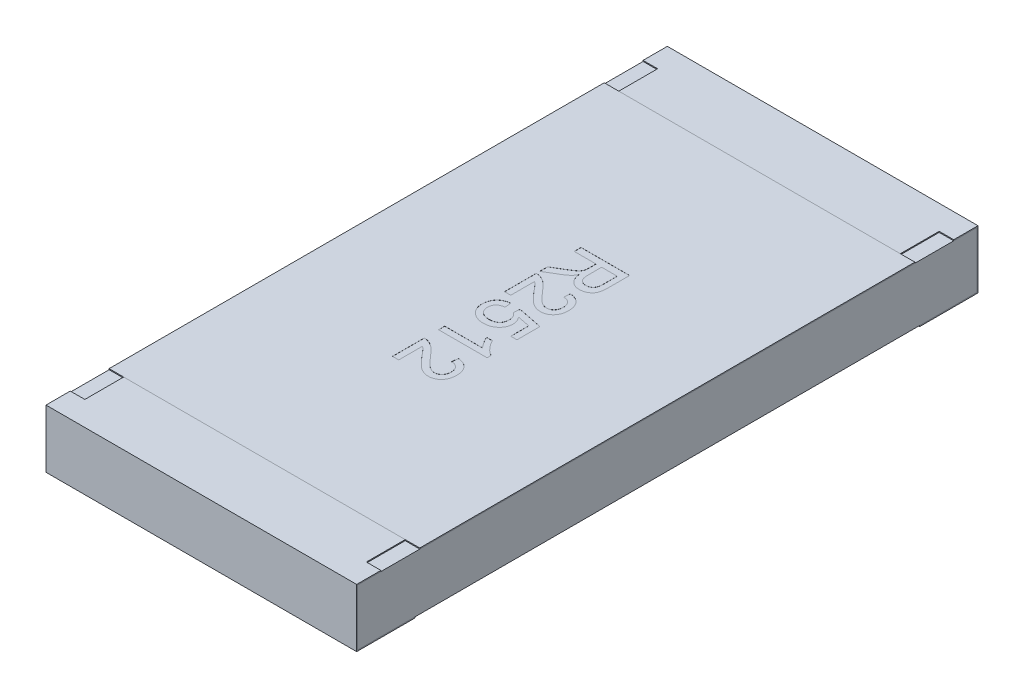
from build123d import *

# Parameters (mm, degrees)
BOSS_EXTRUDE2_DEPTH   = 1.6
BOSS_EXTRUDE2_2_DEPTH = 1.6
BOSS_EXTRUDE3_START   = -1.6
SKETCH5_W             = 6.38
SKETCH5_H             = 0.58
BOSS_EXTRUDE3_DEPTH   = 3.2
SKETCH6_W             = 0.15
SKETCH6_H             = 0.4
CUT_EXTRUDE1_DEPTH    = 0.01
SKETCH7_W             = 3.2
SKETCH7_H             = 5.1
BOSS_EXTRUDE4_DEPTH   = 0.01
TEXT2512_DEPTH        = 0.001


with BuildPart() as part:
    # Sketch4 → Boss-Extrude2 (new body, symmetric)
    with BuildSketch(Plane(origin=(0, 0, 0), x_dir=(0, 0, -1), z_dir=(1, 0, 0))):
        Polygon((-3.2, 0.3), (-3.2, -0.3), (-2.6, -0.3), (-2.6, -0.29), (-3.19, -0.29), (-3.19, 0.29), (-2.55, 0.29), (-2.55, 0.3), align=None)
    extrude(amount=BOSS_EXTRUDE2_DEPTH, both=True)


with BuildPart() as body_2:
    # Sketch4 → Boss-Extrude2 2 (new body, symmetric)
    with BuildSketch(Plane(origin=(0, 0, 0), x_dir=(0, 0, -1), z_dir=(1, 0, 0))):
        Polygon((2.55, 0.3), (3.2, 0.3), (3.2, -0.3), (2.6, -0.3), (2.6, -0.29), (3.19, -0.29), (3.19, 0.29), (2.55, 0.29), align=None)
    extrude(amount=BOSS_EXTRUDE2_2_DEPTH, both=True)


with BuildPart() as body_3:
    # Sketch5 → Boss-Extrude3 (new body)
    with BuildSketch(Plane(origin=(0, 0, 0), x_dir=(0, 0, -1), z_dir=(1, 0, 0)).offset(BOSS_EXTRUDE3_START)):
        Rectangle(SKETCH5_W, SKETCH5_H)
    extrude(amount=BOSS_EXTRUDE3_DEPTH)


with BuildPart() as cut_extrude1_tool:
    # Sketch6 → Cut-Extrude1 (new body)
    with BuildSketch(Plane(origin=(0, 0.3, 0), x_dir=(1, 0, 0), z_dir=(0, 1, 0))):
        with Locations((-1.525, 2.75)):
            Rectangle(SKETCH6_W, SKETCH6_H)
        with Locations((1.525, 2.75)):
            Rectangle(SKETCH6_W, SKETCH6_H)
        with Locations((1.525, -2.75)):
            Rectangle(SKETCH6_W, SKETCH6_H)
        with Locations((-1.525, -2.75)):
            Rectangle(SKETCH6_W, SKETCH6_H)
    extrude(amount=-CUT_EXTRUDE1_DEPTH)


with BuildPart() as part_1:
    add(part.part)

    # Cut-Extrude1: cut by cut_extrude1_tool
    add(cut_extrude1_tool.part, mode=Mode.SUBTRACT)


with BuildPart() as body_2_1:
    add(body_2.part)

    # Cut-Extrude1: cut by cut_extrude1_tool
    add(cut_extrude1_tool.part, mode=Mode.SUBTRACT)


with BuildPart() as body_4:
    # Sketch7 → Boss-Extrude4 (new body)
    with BuildSketch(Plane(origin=(0, 0.29, 0), x_dir=(1, 0, 0), z_dir=(0, 1, 0))):
        Rectangle(SKETCH7_W, SKETCH7_H)
    extrude(amount=BOSS_EXTRUDE4_DEPTH)

    # Sketch16 → TEXT2512 (cut)
    with BuildSketch(Plane(origin=(0, 0.3, 0), x_dir=(1, 0, 0), z_dir=(0, 1, 0))):
        with BuildLine():
            Line((-0.25, 0.961538462), (0.25, 0.961538462))
            Line((0.25, 0.961538462), (0.25, 0.744591346))
            add(Edge.make_bspline(
                [(0.25, 0.744591346), (0.249960163, 0.739482882), (0.249883063, 0.729596046), (0.249332125, 0.71525849), (0.248161656, 0.70190744), (0.246854386, 0.689458751), (0.244924176, 0.677933725), (0.242659692, 0.667326869), (0.239983333, 0.657678866), (0.236819773, 0.648916292), (0.233241826, 0.640785908), (0.228824875, 0.633251678), (0.223992823, 0.62599069), (0.218269952, 0.619290183), (0.212116317, 0.612856855), (0.205227709, 0.606910547), (0.197701412, 0.601422238), (0.18694151, 0.594650155), (0.17253828, 0.58752438), (0.154200832, 0.581442549), (0.134978762, 0.577554129), (0.121846978, 0.577135485), (0.115184295, 0.576923077)],
                knots=[0, 0, 0, 0, 1.5326e-05, 2.9661e-05, 4.3028e-05, 5.5527e-05, 6.7202e-05, 7.8066e-05, 8.8054e-05, 9.721e-05, 0.000105997, 0.000114656, 0.000123379, 0.000132125, 0.00014105, 0.000150068, 0.000159383, 0.00016897, 0.000188187, 0.000207412, 0.0002268, 0.000246768, 0.000246768, 0.000246768, 0.000246768], degree=3))
            add(Edge.make_bspline(
                [(0.115184295, 0.576923077), (0.110907215, 0.577020919), (0.10245969, 0.577214164), (0.090039553, 0.578694416), (0.078172662, 0.581372871), (0.066754852, 0.584807275), (0.055948764, 0.589508619), (0.045530439, 0.594952466), (0.035798164, 0.601706001), (0.026427897, 0.609247173), (0.017837878, 0.618014302), (0.00991265, 0.627773521), (0.003065461, 0.63877045), (-0.003087965, 0.650802727), (-0.008472636, 0.663892184), (-0.013000013, 0.678125865), (-0.016544481, 0.693453368), (-0.01831997, 0.704082614), (-0.019230769, 0.709535256)],
                knots=[0, 0, 0, 0, 1.283e-05, 2.5341e-05, 3.7443e-05, 4.9292e-05, 6.1049e-05, 7.2745e-05, 8.4496e-05, 9.6525e-05, 0.000108778, 0.000121245, 0.000134166, 0.00014756, 0.000161752, 0.000176576, 0.00019232, 0.000208902, 0.000208902, 0.000208902, 0.000208902], degree=3))
            add(Edge.make_bspline(
                [(-0.019230769, 0.709535256), (-0.021256287, 0.705504887), (-0.025089867, 0.697876841), (-0.03124439, 0.687355267), (-0.037334993, 0.678320187), (-0.041788652, 0.673108774), (-0.043870192, 0.670673077)],
                knots=[0, 0, 0, 0, 1.3529e-05, 2.5605e-05, 3.6551e-05, 4.6157e-05, 4.6157e-05, 4.6157e-05, 4.6157e-05], degree=3))
            add(Edge.make_bspline(
                [(-0.043870192, 0.670673077), (-0.048494022, 0.665941745), (-0.057976735, 0.656238563), (-0.074278364, 0.642997304), (-0.09220549, 0.629895236), (-0.105269317, 0.622029028), (-0.111979167, 0.617988782)],
                knots=[0, 0, 0, 0, 1.9831e-05, 4.0671e-05, 6.291e-05, 8.6395e-05, 8.6395e-05, 8.6395e-05, 8.6395e-05], degree=3))
            Line((-0.111979167, 0.617988782), (-0.25, 0.535957532))
            Line((-0.25, 0.535957532), (-0.25, 0.616786859))
            Line((-0.25, 0.616786859), (-0.14443109, 0.679086538))
            add(Edge.make_bspline(
                [(-0.14443109, 0.679086538), (-0.14072714, 0.681326614), (-0.133549493, 0.685667513), (-0.123065864, 0.691936276), (-0.113417718, 0.698088149), (-0.104312641, 0.70377527), (-0.095987375, 0.709301847), (-0.088193556, 0.714357531), (-0.081239279, 0.719331295), (-0.072863649, 0.725115849), (-0.063747422, 0.732089965), (-0.054441051, 0.740283365), (-0.046842147, 0.74788595), (-0.039501217, 0.75739782), (-0.032660963, 0.769200756), (-0.029482057, 0.779212651), (-0.027944712, 0.784054487)],
                knots=[0, 0, 0, 0, 1.2986e-05, 2.5165e-05, 3.6642e-05, 4.7312e-05, 5.7369e-05, 6.6619e-05, 7.5178e-05, 8.3014e-05, 9.7157e-05, 0.000109576, 0.000120201, 0.000129337, 0.000145574, 0.000160781, 0.000160781, 0.000160781, 0.000160781], degree=3))
            add(Edge.make_bspline(
                [(-0.027944712, 0.784054487), (-0.027578209, 0.786086843), (-0.026741472, 0.790726773), (-0.026194997, 0.798605362), (-0.025614988, 0.808151239), (-0.025631888, 0.815069299), (-0.025641026, 0.818810096)],
                knots=[0, 0, 0, 0, 6.191e-06, 1.4135e-05, 2.3663e-05, 3.4882e-05, 3.4882e-05, 3.4882e-05, 3.4882e-05], degree=3))
            Line((-0.025641026, 0.818810096), (-0.025641026, 0.891025641))
            Line((-0.025641026, 0.891025641), (-0.25, 0.891025641))
            Line((-0.25, 0.891025641), (-0.25, 0.961538462))
        make_face()
        with BuildLine():
            Line((0.032051282, 0.891025641), (0.032051282, 0.757111378))
            add(Edge.make_bspline(
                [(0.032051282, 0.757111378), (0.032156765, 0.750396498), (0.032353956, 0.737843659), (0.034025946, 0.720289204), (0.036712066, 0.705301709), (0.0405672, 0.692601432), (0.045943674, 0.681937096), (0.052623746, 0.672775428), (0.060751598, 0.664981424), (0.07009756, 0.658611575), (0.080294979, 0.653594523), (0.091082454, 0.65016958), (0.102226625, 0.647783442), (0.10982965, 0.647552772), (0.113681891, 0.647435897)],
                knots=[0, 0, 0, 0, 2.0141e-05, 3.7652e-05, 5.2837e-05, 6.5761e-05, 7.7318e-05, 8.8497e-05, 9.9618e-05, 0.000110925, 0.000122303, 0.000133579, 0.000144815, 0.000156355, 0.000156355, 0.000156355, 0.000156355], degree=3))
            add(Edge.make_bspline(
                [(0.113681891, 0.647435897), (0.116488464, 0.647528961), (0.121985715, 0.647711246), (0.130054155, 0.648666841), (0.137721037, 0.650524745), (0.14502689, 0.652978104), (0.151918204, 0.656256288), (0.158448379, 0.660150637), (0.164581222, 0.664797798), (0.170335414, 0.670120854), (0.175571167, 0.676232689), (0.180088486, 0.683213842), (0.183927233, 0.691009252), (0.186973919, 0.69962798), (0.189410772, 0.709042877), (0.191031932, 0.719307538), (0.192204997, 0.730375021), (0.192272821, 0.738044145), (0.192307692, 0.741987179)],
                knots=[0, 0, 0, 0, 8.423e-06, 1.6498e-05, 2.4321e-05, 3.205e-05, 3.9577e-05, 4.7169e-05, 5.4822e-05, 6.2617e-05, 7.0646e-05, 7.8897e-05, 8.7497e-05, 9.6653e-05, 0.000106273, 0.000116631, 0.000127803, 0.000139626, 0.000139626, 0.000139626, 0.000139626], degree=3))
            Line((0.192307692, 0.741987179), (0.192307692, 0.891025641))
            Line((0.192307692, 0.891025641), (0.032051282, 0.891025641))
        make_face(mode=Mode.SUBTRACT)
        with BuildLine():
            Line((-0.185897436, 0.173076923), (-0.25, 0.173076923))
            Line((-0.25, 0.173076923), (-0.25, 0.5))
            add(Edge.make_bspline(
                [(-0.25, 0.5), (-0.246190204, 0.500006693), (-0.238583383, 0.500020056), (-0.227333376, 0.49873286), (-0.21623261, 0.496716852), (-0.209114131, 0.494437353), (-0.205528846, 0.493289263)],
                knots=[0, 0, 0, 0, 1.142e-05, 2.2802e-05, 3.392e-05, 4.5202e-05, 4.5202e-05, 4.5202e-05, 4.5202e-05], degree=3))
            add(Edge.make_bspline(
                [(-0.205528846, 0.493289263), (-0.199672194, 0.491165902), (-0.187747085, 0.486842389), (-0.170501435, 0.478116399), (-0.153461868, 0.467682166), (-0.139489569, 0.457696378), (-0.128408004, 0.448499455), (-0.11963342, 0.44091536), (-0.110764129, 0.432372029), (-0.101641984, 0.423025206), (-0.092266458, 0.412931612), (-0.082593861, 0.402091641), (-0.07280804, 0.390373176), (-0.066321448, 0.382192631), (-0.063000801, 0.378004808)],
                knots=[0, 0, 0, 0, 1.8675e-05, 3.8026e-05, 5.7849e-05, 7.8586e-05, 8.9474e-05, 0.000101045, 0.000113371, 0.000126404, 0.000140223, 0.000154696, 0.000169983, 0.000186016, 0.000186016, 0.000186016, 0.000186016], degree=3))
            add(Edge.make_bspline(
                [(-0.063000801, 0.378004808), (-0.057585784, 0.371571255), (-0.047158825, 0.35918304), (-0.031686185, 0.341688941), (-0.017318962, 0.325710928), (-0.003805341, 0.311503434), (0.008723604, 0.298950257), (0.020239487, 0.288021922), (0.03070637, 0.278624397), (0.040503108, 0.270872408), (0.049753955, 0.264331817), (0.058777584, 0.258789244), (0.06773162, 0.254170244), (0.076587728, 0.250323236), (0.085383783, 0.247280579), (0.094145409, 0.245206576), (0.102785672, 0.243800058), (0.108534999, 0.243659335), (0.111378205, 0.243589744)],
                knots=[0, 0, 0, 0, 2.5226e-05, 4.8575e-05, 7.0061e-05, 8.9685e-05, 0.000107391, 0.000123262, 0.00013731, 0.000149574, 0.000160717, 0.000171282, 0.000181316, 0.000190917, 0.000200229, 0.000209193, 0.000217905, 0.000226428, 0.000226428, 0.000226428, 0.000226428], degree=3))
            add(Edge.make_bspline(
                [(0.111378205, 0.243589744), (0.114188238, 0.243659344), (0.119701369, 0.243795895), (0.127769802, 0.245091488), (0.135539896, 0.246895058), (0.14287177, 0.249810882), (0.149982559, 0.253281588), (0.156647535, 0.257733617), (0.163032944, 0.262883656), (0.168969907, 0.268780184), (0.17454131, 0.275219933), (0.179166687, 0.282417853), (0.183368098, 0.289917042), (0.186646742, 0.297965351), (0.189173495, 0.3064911), (0.190933763, 0.315480614), (0.192071797, 0.324957896), (0.192227868, 0.331426935), (0.192307692, 0.334735577)],
                knots=[0, 0, 0, 0, 8.423e-06, 1.6525e-05, 2.4469e-05, 3.23e-05, 4.0139e-05, 4.8167e-05, 5.6286e-05, 6.4714e-05, 7.3243e-05, 8.1771e-05, 9.0332e-05, 9.9e-05, 0.000107778, 0.000116971, 0.00012645, 0.000136374, 0.000136374, 0.000136374, 0.000136374], degree=3))
            add(Edge.make_bspline(
                [(0.192307692, 0.334735577), (0.192227732, 0.338211016), (0.192071243, 0.345012707), (0.190936175, 0.354956033), (0.189191722, 0.364391456), (0.186569692, 0.373285324), (0.183136978, 0.381619852), (0.179045534, 0.389454122), (0.174196706, 0.396758181), (0.168565002, 0.403415143), (0.162430447, 0.40958156), (0.155494268, 0.414790829), (0.148121475, 0.419344442), (0.140077995, 0.422936663), (0.131540513, 0.425866234), (0.122382293, 0.42798081), (0.11264261, 0.429136521), (0.105972365, 0.429368597), (0.102564103, 0.429487179)],
                knots=[0, 0, 0, 0, 1.0424e-05, 2.0401e-05, 2.9987e-05, 3.9178e-05, 4.8162e-05, 5.6988e-05, 6.5655e-05, 7.4401e-05, 8.3113e-05, 9.1687e-05, 0.000100362, 0.000109057, 0.000118053, 0.000127407, 0.000137196, 0.000147425, 0.000147425, 0.000147425, 0.000147425], degree=3))
            Line((0.102564103, 0.429487179), (0.108974359, 0.493589744))
            add(Edge.make_bspline(
                [(0.108974359, 0.493589744), (0.114561103, 0.492933952), (0.125429633, 0.491658166), (0.141170053, 0.488479075), (0.15581619, 0.484020626), (0.169558239, 0.478669774), (0.182228095, 0.472010838), (0.193871977, 0.464291075), (0.20454309, 0.455516505), (0.213993267, 0.445534327), (0.222618938, 0.434726607), (0.229876147, 0.422825241), (0.236164414, 0.410106323), (0.241249058, 0.396479333), (0.245145041, 0.381949617), (0.247930691, 0.366539805), (0.249649875, 0.350232454), (0.249881626, 0.339046748), (0.25, 0.333333333)],
                knots=[0, 0, 0, 0, 1.6871e-05, 3.2822e-05, 4.8095e-05, 6.2751e-05, 7.6998e-05, 9.0943e-05, 0.000104601, 0.000118344, 0.000132109, 0.000146007, 0.000160072, 0.00017462, 0.000189563, 0.000205142, 0.000221557, 0.000238695, 0.000238695, 0.000238695, 0.000238695], degree=3))
            add(Edge.make_bspline(
                [(0.25, 0.333333333), (0.24990096, 0.327551577), (0.249708029, 0.316288681), (0.247735103, 0.299876528), (0.244659885, 0.284392341), (0.240382222, 0.269774143), (0.234732773, 0.2560996), (0.227928529, 0.243321893), (0.219852523, 0.23148148), (0.210540088, 0.220739103), (0.200369372, 0.211051738), (0.189509921, 0.20257465), (0.178049555, 0.19544786), (0.166021375, 0.189553027), (0.153347568, 0.1850393), (0.140075652, 0.181898053), (0.126237909, 0.179753804), (0.116795268, 0.179577236), (0.111979167, 0.179487179)],
                knots=[0, 0, 0, 0, 1.7338e-05, 3.3775e-05, 4.9509e-05, 6.4657e-05, 7.9389e-05, 9.3818e-05, 0.000108014, 0.000122289, 0.000136388, 0.000150092, 0.000163543, 0.000176803, 0.000190204, 0.000203808, 0.000217675, 0.000232111, 0.000232111, 0.000232111, 0.000232111], degree=3))
            add(Edge.make_bspline(
                [(0.111979167, 0.179487179), (0.107030663, 0.179622369), (0.097122734, 0.179893045), (0.082332055, 0.182085171), (0.067657262, 0.18561383), (0.052981733, 0.190510113), (0.038292684, 0.197324189), (0.023237391, 0.205716263), (0.007927337, 0.216205215), (-0.005185376, 0.226152299), (-0.016100688, 0.235517739), (-0.025104319, 0.243819078), (-0.034707985, 0.253420875), (-0.045099702, 0.264067794), (-0.056125829, 0.275977903), (-0.067952516, 0.288934167), (-0.080329296, 0.303193922), (-0.088782578, 0.313094888), (-0.093149038, 0.318209135)],
                knots=[0, 0, 0, 0, 1.484e-05, 2.9713e-05, 4.4751e-05, 6.0081e-05, 7.6038e-05, 9.3257e-05, 0.000111731, 0.000131664, 0.000142604, 0.000154866, 0.000168394, 0.000183339, 0.000199497, 0.000217082, 0.000235964, 0.000256139, 0.000256139, 0.000256139, 0.000256139], degree=3))
            add(Edge.make_bspline(
                [(-0.093149038, 0.318209135), (-0.096714295, 0.32258863), (-0.103512691, 0.330939655), (-0.113369606, 0.342819654), (-0.122404327, 0.353463804), (-0.1303383, 0.363106863), (-0.137487823, 0.371422094), (-0.143708014, 0.378587846), (-0.149086369, 0.384532965), (-0.157337473, 0.393595996), (-0.169000351, 0.405162111), (-0.180421993, 0.413615691), (-0.185897436, 0.417668269)],
                knots=[0, 0, 0, 0, 1.6942e-05, 3.2305e-05, 4.6309e-05, 5.8826e-05, 6.9766e-05, 7.9207e-05, 8.7292e-05, 9.3814e-05, 0.000115985, 0.0001364, 0.0001364, 0.0001364, 0.0001364], degree=3))
            Line((-0.185897436, 0.417668269), (-0.185897436, 0.173076923))
        make_face()
        with BuildLine():
            Line((-0.115384615, 0.102564103), (-0.108974359, 0.038461538))
            add(Edge.make_bspline(
                [(-0.108974359, 0.038461538), (-0.112586187, 0.037826822), (-0.119611753, 0.036592201), (-0.129781469, 0.034239494), (-0.13922942, 0.031183996), (-0.148037429, 0.027750809), (-0.156112364, 0.023669886), (-0.163581723, 0.019248172), (-0.170180368, 0.014033665), (-0.176253413, 0.008551311), (-0.18160484, 0.002534008), (-0.186116278, -0.004076306), (-0.190052234, -0.011095199), (-0.19327482, -0.018608158), (-0.195633584, -0.026626698), (-0.19749896, -0.035048764), (-0.198438915, -0.043982805), (-0.198623748, -0.050078441), (-0.198717949, -0.053185096)],
                knots=[0, 0, 0, 0, 1.1001e-05, 2.1399e-05, 3.1282e-05, 4.0768e-05, 4.9726e-05, 5.8401e-05, 6.6755e-05, 7.4908e-05, 8.2926e-05, 9.0845e-05, 9.887e-05, 0.000107038, 0.000115307, 0.000123912, 0.000132882, 0.000142206, 0.000142206, 0.000142206, 0.000142206], degree=3))
            add(Edge.make_bspline(
                [(-0.198717949, -0.053185096), (-0.19862586, -0.056996266), (-0.198445776, -0.064449175), (-0.196922698, -0.075291747), (-0.19441132, -0.085533433), (-0.190896833, -0.09512523), (-0.186526152, -0.104179583), (-0.180866916, -0.112396119), (-0.174505377, -0.120222849), (-0.1669212, -0.127156121), (-0.158664557, -0.133467346), (-0.14965208, -0.138914408), (-0.140010266, -0.143500065), (-0.129740964, -0.147360686), (-0.118785509, -0.150211474), (-0.107202181, -0.152308458), (-0.094983602, -0.153654638), (-0.086608825, -0.15378141), (-0.082331731, -0.153846154)],
                knots=[0, 0, 0, 0, 1.1429e-05, 2.235e-05, 3.2772e-05, 4.3006e-05, 5.2951e-05, 6.284e-05, 7.2869e-05, 8.3144e-05, 9.3581e-05, 0.000104008, 0.00011467, 0.000125572, 0.00013687, 0.000148579, 0.000160867, 0.000173694, 0.000173694, 0.000173694, 0.000173694], degree=3))
            add(Edge.make_bspline(
                [(-0.082331731, -0.153846154), (-0.078255716, -0.153772567), (-0.07031877, -0.153629277), (-0.058761256, -0.152422538), (-0.047893696, -0.150386627), (-0.037596309, -0.14775235), (-0.028030005, -0.14412133), (-0.019056083, -0.139814737), (-0.010864994, -0.134538979), (-0.003201699, -0.12866935), (0.003668137, -0.121965493), (0.009468842, -0.11433684), (0.014545632, -0.106082658), (0.018662591, -0.097036699), (0.021721337, -0.087193637), (0.024074767, -0.076651285), (0.025312575, -0.06530025), (0.025529575, -0.057494552), (0.025641026, -0.053485577)],
                knots=[0, 0, 0, 0, 1.2226e-05, 2.3807e-05, 3.4808e-05, 4.5377e-05, 5.5646e-05, 6.5456e-05, 7.5181e-05, 8.4818e-05, 9.4379e-05, 0.000103876, 0.000113495, 0.000123401, 0.000133601, 0.000144367, 0.00015576, 0.000167789, 0.000167789, 0.000167789, 0.000167789], degree=3))
            add(Edge.make_bspline(
                [(0.025641026, -0.053485577), (0.025491387, -0.048501405), (0.025203425, -0.038909959), (0.022894783, -0.025162111), (0.019038767, -0.012672912), (0.01340113, -0.001566177), (0.006631659, 0.008378684), (-0.001024126, 0.01734517), (-0.009565812, 0.025405836), (-0.015996531, 0.02982748), (-0.019230769, 0.032051282)],
                knots=[0, 0, 0, 0, 1.4945e-05, 2.8761e-05, 4.1685e-05, 5.4003e-05, 6.5976e-05, 7.7698e-05, 8.9321e-05, 0.000101081, 0.000101081, 0.000101081, 0.000101081], degree=3))
            Line((-0.019230769, 0.032051282), (-0.012820513, 0.096153846))
            Line((-0.012820513, 0.096153846), (0.243589744, 0.044871795))
            Line((0.243589744, 0.044871795), (0.243589744, -0.192307692))
            Line((0.243589744, -0.192307692), (0.179487179, -0.192307692))
            Line((0.179487179, -0.192307692), (0.179487179, -0.007512019))
            Line((0.179487179, -0.007512019), (0.049979968, 0.017928686))
            add(Edge.make_bspline(
                [(0.049979968, 0.017928686), (0.052633796, 0.014391519), (0.057845494, 0.007445083), (0.064676088, -0.003387375), (0.070394853, -0.014357876), (0.075181731, -0.025408727), (0.078783961, -0.036693128), (0.081359847, -0.048088137), (0.08307819, -0.059610163), (0.083248043, -0.067334987), (0.083333333, -0.071213942)],
                knots=[0, 0, 0, 0, 1.3262e-05, 2.6045e-05, 3.8365e-05, 5.0347e-05, 6.213e-05, 7.3841e-05, 8.5372e-05, 9.7001e-05, 9.7001e-05, 9.7001e-05, 9.7001e-05], degree=3))
            add(Edge.make_bspline(
                [(0.083333333, -0.071213942), (0.083201063, -0.076262289), (0.08294059, -0.086203708), (0.080800473, -0.100852729), (0.077167497, -0.114859675), (0.072274361, -0.12833433), (0.065787848, -0.141099331), (0.05793341, -0.153282781), (0.048649322, -0.164840083), (0.038099128, -0.175688124), (0.026437841, -0.185568095), (0.013856148, -0.194227164), (0.000442132, -0.201594647), (-0.013788726, -0.207598467), (-0.028861807, -0.212229812), (-0.044692889, -0.215484058), (-0.061343963, -0.217552338), (-0.072710105, -0.217814554), (-0.078525641, -0.217948718)],
                knots=[0, 0, 0, 0, 1.514e-05, 2.9815e-05, 4.4294e-05, 5.849e-05, 7.2735e-05, 8.7154e-05, 0.000101905, 0.000117133, 0.000132484, 0.000147681, 0.000162877, 0.000178318, 0.000193937, 0.000210103, 0.000226751, 0.000244193, 0.000244193, 0.000244193, 0.000244193], degree=3))
            add(Edge.make_bspline(
                [(-0.078525641, -0.217948718), (-0.084072884, -0.217836269), (-0.095030272, -0.21761415), (-0.111172579, -0.215761686), (-0.126756663, -0.21278891), (-0.141710465, -0.208535612), (-0.156166252, -0.203257401), (-0.169945746, -0.196570051), (-0.18332252, -0.188924355), (-0.191564851, -0.182779932), (-0.195713141, -0.1796875)],
                knots=[0, 0, 0, 0, 1.6637e-05, 3.2864e-05, 4.8677e-05, 6.4182e-05, 7.9457e-05, 9.4779e-05, 0.000110085, 0.000125594, 0.000125594, 0.000125594, 0.000125594], degree=3))
            add(Edge.make_bspline(
                [(-0.195713141, -0.1796875), (-0.200555889, -0.175759844), (-0.210082093, -0.168033722), (-0.222446537, -0.154656027), (-0.232954612, -0.140274815), (-0.241491662, -0.124804503), (-0.248351904, -0.108348946), (-0.252917137, -0.090705993), (-0.255982873, -0.072088829), (-0.256265835, -0.059307785), (-0.256410256, -0.052784455)],
                knots=[0, 0, 0, 0, 1.8686e-05, 3.6757e-05, 5.4468e-05, 7.1998e-05, 8.965e-05, 0.000107799, 0.000126555, 0.000146107, 0.000146107, 0.000146107, 0.000146107], degree=3))
            add(Edge.make_bspline(
                [(-0.256410256, -0.052784455), (-0.256301101, -0.047403749), (-0.256087571, -0.036878006), (-0.254231508, -0.021466356), (-0.251271122, -0.006808399), (-0.247027162, 0.007102053), (-0.241657017, 0.020301146), (-0.234875977, 0.032632177), (-0.227022789, 0.044259002), (-0.217999763, 0.055031487), (-0.208043427, 0.064976767), (-0.197057937, 0.073675716), (-0.185346654, 0.081325758), (-0.172944192, 0.088028278), (-0.159606333, 0.093245894), (-0.145600701, 0.097614269), (-0.130789038, 0.100853553), (-0.120573263, 0.101987941), (-0.115384615, 0.102564103)],
                knots=[0, 0, 0, 0, 1.6137e-05, 3.1567e-05, 4.6496e-05, 6.0944e-05, 7.5136e-05, 8.9165e-05, 0.000103083, 0.000117164, 0.000131258, 0.000145227, 0.000159117, 0.000173187, 0.000187434, 0.000202007, 0.000217173, 0.000232827, 0.000232827, 0.000232827, 0.000232827], degree=3))
        make_face()
        with BuildLine():
            Line((-0.25, -0.506410256), (-0.25, -0.442307692))
            Line((-0.25, -0.442307692), (0.139623397, -0.442307692))
            add(Edge.make_bspline(
                [(0.139623397, -0.442307692), (0.136064182, -0.438616449), (0.128666742, -0.430944606), (0.118190939, -0.417980505), (0.107619408, -0.403514084), (0.097315673, -0.387785327), (0.08780582, -0.371628763), (0.079128194, -0.356062824), (0.071822591, -0.341304921), (0.067824115, -0.33158647), (0.065905449, -0.326923077)],
                knots=[0, 0, 0, 0, 1.5377e-05, 3.1959e-05, 4.9949e-05, 6.9117e-05, 8.8339e-05, 0.000106181, 0.000122576, 0.0001377, 0.0001377, 0.0001377, 0.0001377], degree=3))
            Line((0.065905449, -0.326923077), (0.125, -0.326923077))
            add(Edge.make_bspline(
                [(0.125, -0.326923077), (0.129125269, -0.334933277), (0.137255931, -0.350720908), (0.151298701, -0.373025416), (0.166521642, -0.393849074), (0.182921383, -0.412847168), (0.199684862, -0.429877748), (0.216599871, -0.444229665), (0.233046379, -0.456238436), (0.244515995, -0.462263464), (0.25, -0.465144231)],
                knots=[0, 0, 0, 0, 2.702e-05, 5.3254e-05, 7.8977e-05, 0.000104333, 0.000128484, 0.000150581, 0.000170841, 0.000189403, 0.000189403, 0.000189403, 0.000189403], degree=3))
            Line((0.25, -0.465144231), (0.25, -0.506410256))
            Line((0.25, -0.506410256), (-0.25, -0.506410256))
        make_face()
        with BuildLine():
            Line((-0.185897436, -0.980769231), (-0.25, -0.980769231))
            Line((-0.25, -0.980769231), (-0.25, -0.653846154))
            add(Edge.make_bspline(
                [(-0.25, -0.653846154), (-0.246190204, -0.653839461), (-0.238583383, -0.653826097), (-0.227333376, -0.655113294), (-0.21623261, -0.657129302), (-0.209114131, -0.659408801), (-0.205528846, -0.660556891)],
                knots=[0, 0, 0, 0, 1.142e-05, 2.2802e-05, 3.392e-05, 4.5202e-05, 4.5202e-05, 4.5202e-05, 4.5202e-05], degree=3))
            add(Edge.make_bspline(
                [(-0.205528846, -0.660556891), (-0.199672194, -0.662680252), (-0.187747085, -0.667003765), (-0.170501435, -0.675729754), (-0.153461868, -0.686163988), (-0.139489569, -0.696149776), (-0.128408004, -0.705346699), (-0.11963342, -0.712930794), (-0.110764129, -0.721474124), (-0.101641984, -0.730820948), (-0.092266458, -0.740914542), (-0.082593861, -0.751754513), (-0.07280804, -0.763472978), (-0.066321448, -0.771653523), (-0.063000801, -0.775841346)],
                knots=[0, 0, 0, 0, 1.8675e-05, 3.8026e-05, 5.7849e-05, 7.8586e-05, 8.9474e-05, 0.000101045, 0.000113371, 0.000126404, 0.000140223, 0.000154696, 0.000169983, 0.000186016, 0.000186016, 0.000186016, 0.000186016], degree=3))
            add(Edge.make_bspline(
                [(-0.063000801, -0.775841346), (-0.057585784, -0.782274899), (-0.047158825, -0.794663113), (-0.031686185, -0.812157213), (-0.017318962, -0.828135226), (-0.003805341, -0.842342719), (0.008723604, -0.854895897), (0.020239487, -0.865824232), (0.03070637, -0.875221757), (0.040503108, -0.882973746), (0.049753955, -0.889514337), (0.058777584, -0.89505691), (0.06773162, -0.89967591), (0.076587728, -0.903522918), (0.085383783, -0.906565575), (0.094145409, -0.908639578), (0.102785672, -0.910046095), (0.108534999, -0.910186819), (0.111378205, -0.91025641)],
                knots=[0, 0, 0, 0, 2.5226e-05, 4.8575e-05, 7.0061e-05, 8.9685e-05, 0.000107391, 0.000123262, 0.00013731, 0.000149574, 0.000160717, 0.000171282, 0.000181316, 0.000190917, 0.000200229, 0.000209193, 0.000217905, 0.000226428, 0.000226428, 0.000226428, 0.000226428], degree=3))
            add(Edge.make_bspline(
                [(0.111378205, -0.91025641), (0.114188238, -0.91018681), (0.119701369, -0.910050259), (0.127769802, -0.908754665), (0.135539896, -0.906951096), (0.14287177, -0.904035271), (0.149982559, -0.900564566), (0.156647535, -0.896112537), (0.163032944, -0.890962498), (0.168969907, -0.88506597), (0.17454131, -0.87862622), (0.179166687, -0.871428301), (0.183368098, -0.863929112), (0.186646742, -0.855880802), (0.189173495, -0.847355054), (0.190933763, -0.83836554), (0.192071797, -0.828888258), (0.192227868, -0.822419219), (0.192307692, -0.819110577)],
                knots=[0, 0, 0, 0, 8.423e-06, 1.6525e-05, 2.4469e-05, 3.23e-05, 4.0139e-05, 4.8167e-05, 5.6286e-05, 6.4714e-05, 7.3243e-05, 8.1771e-05, 9.0332e-05, 9.9e-05, 0.000107778, 0.000116971, 0.00012645, 0.000136374, 0.000136374, 0.000136374, 0.000136374], degree=3))
            add(Edge.make_bspline(
                [(0.192307692, -0.819110577), (0.192227732, -0.815635137), (0.192071243, -0.808833447), (0.190936175, -0.798890121), (0.189191722, -0.789454698), (0.186569692, -0.78056083), (0.183136978, -0.772226302), (0.179045534, -0.764392031), (0.174196706, -0.757087973), (0.168565002, -0.750431011), (0.162430447, -0.744264593), (0.155494268, -0.739055325), (0.148121475, -0.734501712), (0.140077995, -0.73090949), (0.131540513, -0.72797992), (0.122382293, -0.725865344), (0.11264261, -0.724709632), (0.105972365, -0.724477557), (0.102564103, -0.724358974)],
                knots=[0, 0, 0, 0, 1.0424e-05, 2.0401e-05, 2.9987e-05, 3.9178e-05, 4.8162e-05, 5.6988e-05, 6.5655e-05, 7.4401e-05, 8.3113e-05, 9.1687e-05, 0.000100362, 0.000109057, 0.000118053, 0.000127407, 0.000137196, 0.000147425, 0.000147425, 0.000147425, 0.000147425], degree=3))
            Line((0.102564103, -0.724358974), (0.108974359, -0.66025641))
            add(Edge.make_bspline(
                [(0.108974359, -0.66025641), (0.114561103, -0.660912202), (0.125429633, -0.662187987), (0.141170053, -0.665367079), (0.15581619, -0.669825528), (0.169558239, -0.675176379), (0.182228095, -0.681835316), (0.193871977, -0.689555079), (0.20454309, -0.698329649), (0.213993267, -0.708311826), (0.222618938, -0.719119547), (0.229876147, -0.731020913), (0.236164414, -0.74373983), (0.241249058, -0.757366821), (0.245145041, -0.771896537), (0.247930691, -0.787306349), (0.249649875, -0.8036137), (0.249881626, -0.814799406), (0.25, -0.820512821)],
                knots=[0, 0, 0, 0, 1.6871e-05, 3.2822e-05, 4.8095e-05, 6.2751e-05, 7.6998e-05, 9.0943e-05, 0.000104601, 0.000118344, 0.000132109, 0.000146007, 0.000160072, 0.00017462, 0.000189563, 0.000205142, 0.000221557, 0.000238695, 0.000238695, 0.000238695, 0.000238695], degree=3))
            add(Edge.make_bspline(
                [(0.25, -0.820512821), (0.24990096, -0.826294577), (0.249708029, -0.837557473), (0.247735103, -0.853969625), (0.244659885, -0.869453813), (0.240382222, -0.884072011), (0.234732773, -0.897746554), (0.227928529, -0.910524261), (0.219852523, -0.922364674), (0.210540088, -0.933107051), (0.200369372, -0.942794416), (0.189509921, -0.951271504), (0.178049555, -0.958398294), (0.166021375, -0.964293127), (0.153347568, -0.968806854), (0.140075652, -0.971948101), (0.126237909, -0.97409235), (0.116795268, -0.974268918), (0.111979167, -0.974358974)],
                knots=[0, 0, 0, 0, 1.7338e-05, 3.3775e-05, 4.9509e-05, 6.4657e-05, 7.9389e-05, 9.3818e-05, 0.000108014, 0.000122289, 0.000136388, 0.000150092, 0.000163543, 0.000176803, 0.000190204, 0.000203808, 0.000217675, 0.000232111, 0.000232111, 0.000232111, 0.000232111], degree=3))
            add(Edge.make_bspline(
                [(0.111979167, -0.974358974), (0.107030663, -0.974223785), (0.097122734, -0.973953109), (0.082332055, -0.971760983), (0.067657262, -0.968232324), (0.052981733, -0.963336041), (0.038292684, -0.956521965), (0.023237391, -0.948129891), (0.007927337, -0.937640939), (-0.005185376, -0.927693855), (-0.016100688, -0.918328415), (-0.025104319, -0.910027076), (-0.034707985, -0.900425279), (-0.045099702, -0.88977836), (-0.056125829, -0.877868251), (-0.067952516, -0.864911987), (-0.080329296, -0.850652232), (-0.088782578, -0.840751266), (-0.093149038, -0.835637019)],
                knots=[0, 0, 0, 0, 1.484e-05, 2.9713e-05, 4.4751e-05, 6.0081e-05, 7.6038e-05, 9.3257e-05, 0.000111731, 0.000131664, 0.000142604, 0.000154866, 0.000168394, 0.000183339, 0.000199497, 0.000217082, 0.000235964, 0.000256139, 0.000256139, 0.000256139, 0.000256139], degree=3))
            add(Edge.make_bspline(
                [(-0.093149038, -0.835637019), (-0.096714295, -0.831257523), (-0.103512691, -0.822906499), (-0.113369606, -0.8110265), (-0.122404327, -0.80038235), (-0.1303383, -0.790739291), (-0.137487823, -0.78242406), (-0.143708014, -0.775258308), (-0.149086369, -0.769313189), (-0.157337473, -0.760250158), (-0.169000351, -0.748684043), (-0.180421993, -0.740230463), (-0.185897436, -0.736177885)],
                knots=[0, 0, 0, 0, 1.6942e-05, 3.2305e-05, 4.6309e-05, 5.8826e-05, 6.9766e-05, 7.9207e-05, 8.7292e-05, 9.3814e-05, 0.000115985, 0.0001364, 0.0001364, 0.0001364, 0.0001364], degree=3))
            Line((-0.185897436, -0.736177885), (-0.185897436, -0.980769231))
        make_face()
    extrude(amount=-TEXT2512_DEPTH, mode=Mode.SUBTRACT)


solid = Compound([body_3.part, part_1.part, body_2_1.part, body_4.part])
